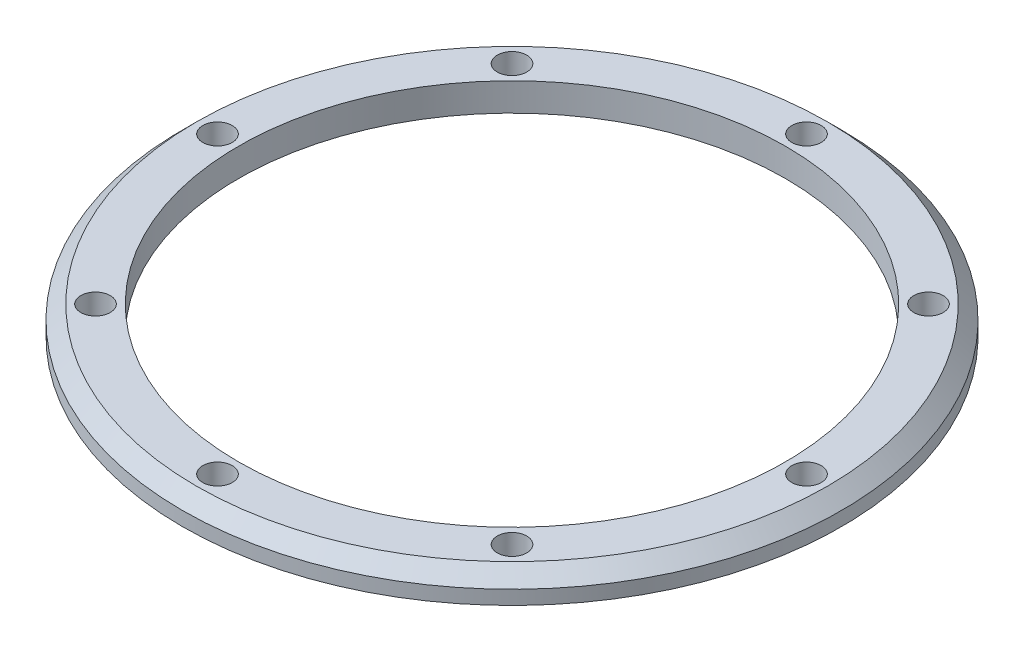
from build123d import *

# Parameters (mm, degrees)
SKETCH_2_R          = 2.1
CUT_EXTRUDE_1_DEPTH = 10


with BuildPart() as part:
    # 草图1 → 旋转1 (revolve)
    with BuildSketch(Plane.XY):
        Polygon((-39, 0), (-47, 0), (-47, 2), (-45, 4), (-39, 4), align=None)
    revolve(axis=Axis((0, 0, 0), (0, 1, 0)))

    # 草图2 → 切除-拉伸1 (cut)
    with BuildSketch(Plane.XZ):
        with Locations((0, 42)):
            Circle(SKETCH_2_R)
        with Locations((29.69848481, 29.69848481)):
            Circle(SKETCH_2_R)
        with Locations((42, 0)):
            Circle(SKETCH_2_R)
        with Locations((29.69848481, -29.69848481)):
            Circle(SKETCH_2_R)
        with Locations((0, -42)):
            Circle(SKETCH_2_R)
        with Locations((-29.69848481, -29.69848481)):
            Circle(SKETCH_2_R)
        with Locations((-42, 0)):
            Circle(SKETCH_2_R)
        with Locations((-29.69848481, 29.69848481)):
            Circle(SKETCH_2_R)
    extrude(amount=-CUT_EXTRUDE_1_DEPTH, mode=Mode.SUBTRACT)


solid = part.part
